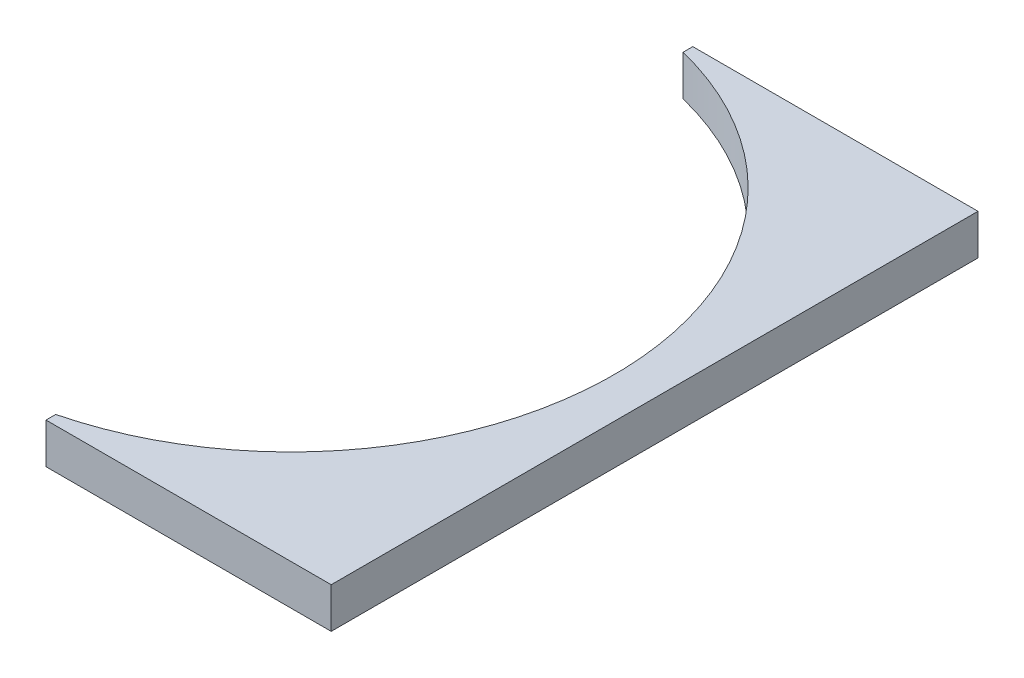
from build123d import *

# Parameters (mm, degrees)
BOSS_EXTRUDE1_DEPTH = 3.175


with BuildPart() as part:
    # Sketch1 → Boss-Extrude1 (new body)
    with BuildSketch(Plane(origin=(0, 0, 0), x_dir=(1, 0, 0), z_dir=(0, 1, 0))):
        with BuildLine():
            Line((28.575, 25.4), (6.174864857, 25.4))
            Line((6.174864857, 25.4), (6.174864857, 24.638))
            ThreePointArc((6.174864857, 24.638), (20.025003962, 15.625594911), (25.4, 0))
            ThreePointArc((25.4, 0), (20.025003962, -15.625594911), (6.174864857, -24.638))
            Line((6.174864857, -24.638), (6.174864857, -25.4))
            Line((6.174864857, -25.4), (28.575, -25.4))
            Line((28.575, -25.4), (28.575, 25.4))
        make_face()
    extrude(amount=BOSS_EXTRUDE1_DEPTH)


solid = part.part
